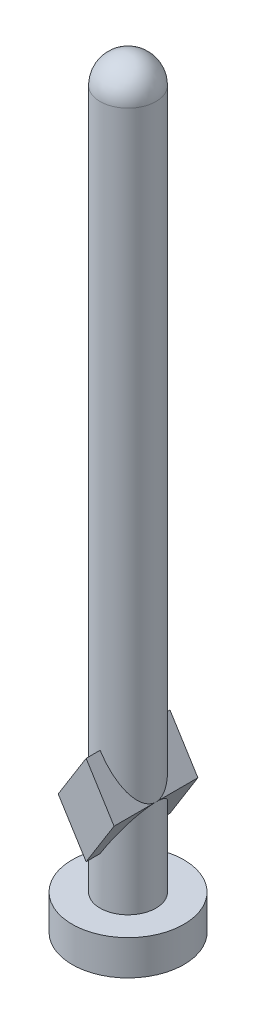
from build123d import *

# Parameters (mm, degrees)
SKETCH1_R                = 4
BOSS_EXTRUDE1_DEPTH      = 100
DOME1_FACE_RADIUS        = 4
DOME1_HEIGHT             = 4
SKETCH2_R                = 8
BOSS_EXTRUDE2_DEPTH      = 5
BOSS_EXTRUDE3_DEPTH      = 6
BOSS_EXTRUDE3_DEPTH_BACK = 6


with BuildPart() as part:
    # Sketch1 → Boss-Extrude1 (new body)
    with BuildSketch(Plane(origin=(0, 0, 0), x_dir=(1, 0, 0), z_dir=(0, 1, 0))):
        Circle(SKETCH1_R)
    extrude(amount=BOSS_EXTRUDE1_DEPTH)

    # Dome1: a dome of height H over a round flat face of radius A is a cap of a sphere of radius (A * A + H * H) / (2 * H)
    dome1_r = (DOME1_FACE_RADIUS * DOME1_FACE_RADIUS + DOME1_HEIGHT * DOME1_HEIGHT) / (2 * DOME1_HEIGHT)
    dome1_base = Plane((0, 100, 0), z_dir=(0, 1, 0))
    with Locations(dome1_base.offset(DOME1_HEIGHT - dome1_r)):
        dome1_ball = Sphere(dome1_r, mode=Mode.PRIVATE)
    add(split(dome1_ball, bisect_by=dome1_base, keep=Keep.TOP, mode=Mode.PRIVATE))

    # Sketch2 → Boss-Extrude2 (add)
    with BuildSketch(Plane.XZ):
        Circle(SKETCH2_R)
    extrude(amount=BOSS_EXTRUDE2_DEPTH)

    # Sketch3 → Boss-Extrude3 (add, two sides)
    with BuildSketch(Plane.XY) as boss_extrude3_sk:
        Polygon((-4, 13.165812433), (0, 6.759409677), (4, 13.165812433), (0, 19.572215189), align=None)
    extrude(amount=BOSS_EXTRUDE3_DEPTH)
    extrude(boss_extrude3_sk.sketch, amount=-BOSS_EXTRUDE3_DEPTH_BACK)


solid = part.part
